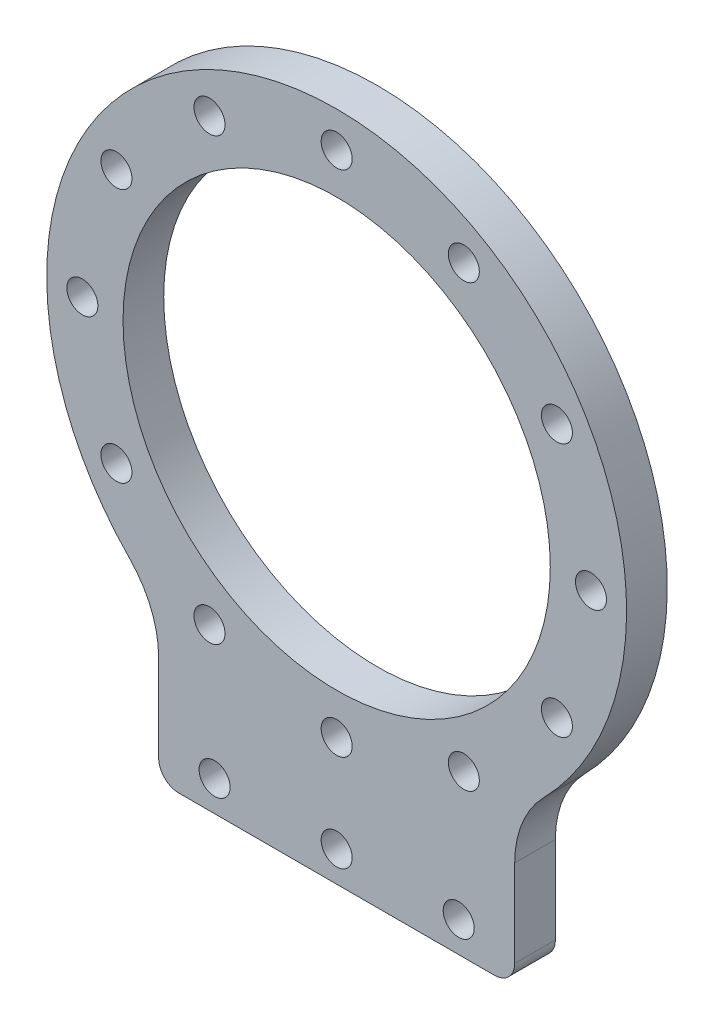
from build123d import *

# Parameters (mm, degrees)
SKETCH_2_R          = 1.525
EXTRUDE_1_DEPTH     = 4
SKETCH_4_R          = 21
CUT_EXTRUDE_1_DEPTH = 5
SKETCH_5_R          = 1.525
CUT_EXTRUDE_2_DEPTH = 5
FILLET_1_R          = 2
FILLET_2_R          = 10


with BuildPart() as part:
    # 草图2 → 凸台-拉伸1 (new body)
    with BuildSketch(Plane.XY):
        with BuildLine():
            ThreePointArc((17.5, -22.494443758), (0, 28.5), (-17.5, -22.494443758))
            Line((-17.5, -22.494443758), (-17.5, -37.5))
            Line((-17.5, -37.5), (17.5, -37.5))
            Line((17.5, -37.5), (17.5, -22.494443758))
        make_face()
        with Locations((-12.5, -21.650635095)):
            Circle(SKETCH_2_R, mode=Mode.SUBTRACT)
        with Locations((12.5, -21.650635095)):
            Circle(SKETCH_2_R, mode=Mode.SUBTRACT)
        with Locations((-21.650635095, -12.5)):
            Circle(SKETCH_2_R, mode=Mode.SUBTRACT)
        with Locations((21.650635095, -12.5)):
            Circle(SKETCH_2_R, mode=Mode.SUBTRACT)
        with Locations((-25, 0)):
            Circle(SKETCH_2_R, mode=Mode.SUBTRACT)
        with Locations((-21.650635095, 12.5)):
            Circle(SKETCH_2_R, mode=Mode.SUBTRACT)
        with Locations((-12.5, 21.650635095)):
            Circle(SKETCH_2_R, mode=Mode.SUBTRACT)
        with Locations((25, 0)):
            Circle(SKETCH_2_R, mode=Mode.SUBTRACT)
        with Locations((0, 25)):
            Circle(SKETCH_2_R, mode=Mode.SUBTRACT)
        with Locations((12.5, 21.650635095)):
            Circle(SKETCH_2_R, mode=Mode.SUBTRACT)
        with Locations((21.650635095, 12.5)):
            Circle(SKETCH_2_R, mode=Mode.SUBTRACT)
        with Locations((0, -25)):
            Circle(SKETCH_2_R, mode=Mode.SUBTRACT)
    extrude(amount=EXTRUDE_1_DEPTH)

    # 草图4 → 切除-拉伸1 (cut, through all)
    with BuildSketch(Plane.XY.offset(4)):
        Circle(SKETCH_4_R)
    extrude(amount=-CUT_EXTRUDE_1_DEPTH, mode=Mode.SUBTRACT)

    # 草图5 → 切除-拉伸2 (cut, through all)
    with BuildSketch(Plane.XY.offset(4)):
        with Locations((0, -34.5)):
            Circle(SKETCH_5_R)
        with Locations((12, -34.5)):
            Circle(SKETCH_5_R)
        with Locations((-12, -34.5)):
            Circle(SKETCH_5_R)
    extrude(amount=-CUT_EXTRUDE_2_DEPTH, mode=Mode.SUBTRACT)

    # 圆角1
    fillet_1_edges = [part.edges().sort_by_distance(p)[0] for p in [
        (17.5, -37.5, 2),
        (-17.5, -37.5, 2),
    ]]
    fillet(fillet_1_edges, radius=FILLET_1_R)

    # 圆角2
    fillet_2_edges = [part.edges().sort_by_distance(p)[0] for p in [
        (17.5, -22.494443758, 2),
        (-17.5, -22.494443758, 2),
    ]]
    fillet(fillet_2_edges, radius=FILLET_2_R)


solid = part.part
